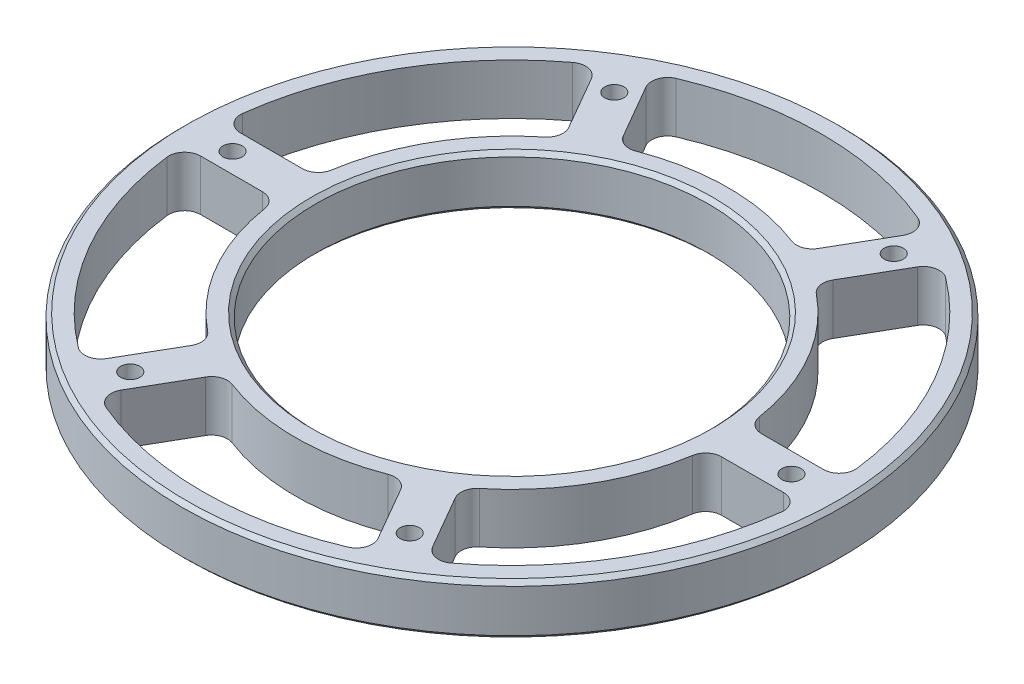
from build123d import *

# Parameters (mm, degrees)
SKETCH2_W                   = 33.3375
SKETCH2_H                   = 12.7
F_12_0_189_DIAMETER_HOLE1_D = 4.8006
CIRPATTERN3_COUNT           = 6
CUT_EXTRUDE1_DEPTH          = 13.7
FILLET1_R                   = 4
CIRPATTERN4_COUNT           = 6
FILLET1_OF_CIRPATTERN4_R    = 4
CHAMFER1_SIZE               = 1
CHAMFER2_SIZE               = 1


with BuildPart() as part:
    # Sketch2 → Revolve1 (revolve)
    with BuildSketch(Plane(origin=(0, 0, 0), x_dir=(0, 0, -1), z_dir=(1, 0, 0))):
        with Locations((-65.88125, 6.35)):
            Rectangle(SKETCH2_W, SKETCH2_H)
    revolve(axis=Axis((0, -0.635, 0), (0, 1, 0)))

    # #12 (0.189) Diameter Hole1 (through all)
    with Locations(Plane(origin=(0, 12.7, 0), x_dir=(1, 0, 0), z_dir=(0, 1, 0))):
        with Locations((-35, 60.621778)):
            f_12_0_189_diameter_hole1 = Hole(F_12_0_189_DIAMETER_HOLE1_D / 2)

    # CirPattern3: #12 (0.189) Diameter Hole1 ×6 about axis
    cirpattern3_axis = Axis((0, 0, 0), (0, 1, 0))
    for i in range(1, CIRPATTERN3_COUNT):
        add(f_12_0_189_diameter_hole1.rotate(cirpattern3_axis, i * 360 / CIRPATTERN3_COUNT), mode=Mode.SUBTRACT)

    # Sketch8 → Cut-Extrude1 (cut, through all)
    with BuildSketch(Plane(origin=(0, 12.7, 0), x_dir=(1, 0, 0), z_dir=(0, 1, 0))):
        with BuildLine():
            Line((-22.66059, 49.249293), (-34.364196, 69.520533))
            ThreePointArc((-34.364196, 69.520533), (0, 77.55), (34.364196, 69.520533))
            Line((34.364196, 69.520533), (22.66059, 49.249293))
            ThreePointArc((22.66059, 49.249293), (0, 54.2125), (-22.66059, 49.249293))
        make_face()
    cut_extrude1 = extrude(amount=-CUT_EXTRUDE1_DEPTH, mode=Mode.SUBTRACT)

    # Fillet1
    fillet1_edges = [part.edges().sort_by_distance(p)[0] for p in [
        (22.66059, 6.35, -49.249293),
        (-22.66059, 6.35, -49.249293),
        (-34.364196, 6.35, -69.520533),
        (34.364196, 6.35, -69.520533),
    ]]
    fillet(fillet1_edges, radius=FILLET1_R)

    # CirPattern4: Cut-Extrude1 ×6 about axis
    cirpattern4_axis = Axis((0, 0, 0), (0, 1, 0))
    for i in range(1, CIRPATTERN4_COUNT):
        add(cut_extrude1.rotate(cirpattern4_axis, i * 360 / CIRPATTERN4_COUNT), mode=Mode.SUBTRACT)

    # Fillet1 of CirPattern4
    fillet1_of_cirpattern4_edges = [part.edges().sort_by_distance(p)[0] for p in [
        (-31.320844, 6.35, -44.249293),
        (-53.981433, 6.35, -5),
        (-77.388646, 6.35, -5),
        (-43.02445, 6.35, -64.520533),
        (-53.981433, 6.35, 5),
        (-31.320844, 6.35, 44.249293),
        (-43.02445, 6.35, 64.520533),
        (-77.388646, 6.35, 5),
        (-22.66059, 6.35, 49.249293),
        (22.66059, 6.35, 49.249293),
        (34.364196, 6.35, 69.520533),
        (-34.364196, 6.35, 69.520533),
        (31.320844, 6.35, 44.249293),
        (53.981433, 6.35, 5),
        (77.388646, 6.35, 5),
        (43.02445, 6.35, 64.520533),
        (53.981433, 6.35, -5),
        (31.320844, 6.35, -44.249293),
        (43.02445, 6.35, -64.520533),
        (77.388646, 6.35, -5),
    ]]
    fillet(fillet1_of_cirpattern4_edges, radius=FILLET1_OF_CIRPATTERN4_R)

    # Chamfer1
    chamfer1_edges = [part.edges().sort_by_distance(p)[0] for p in [
        (0, 12.7, -49.2125),
        (0, 0, -49.2125),
    ]]
    chamfer(chamfer1_edges, length=CHAMFER1_SIZE)

    # Chamfer2
    chamfer2_edges = [part.edges().sort_by_distance(p)[0] for p in [
        (0, 12.7, -82.55),
        (0, 0, -82.55),
    ]]
    chamfer(chamfer2_edges, length=CHAMFER2_SIZE)


solid = part.part
